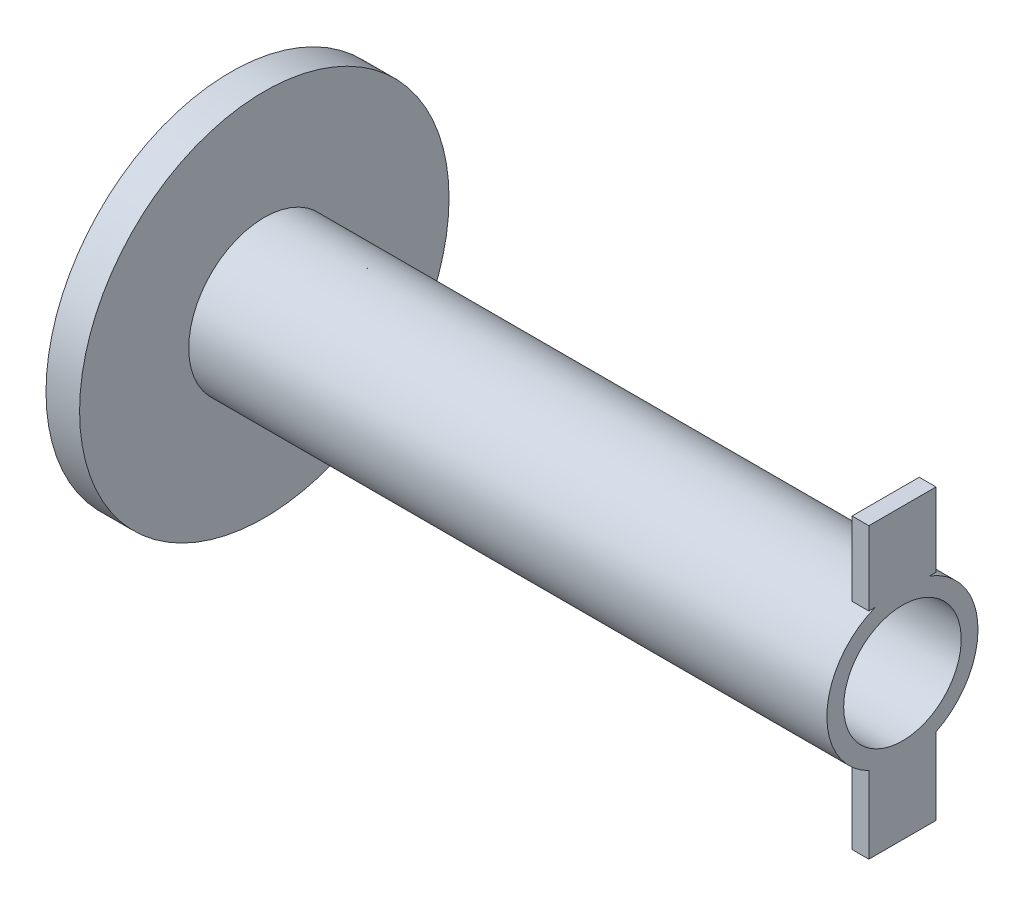
from build123d import *

# Parameters (mm, degrees)
SKETCH2_R               = 55
BOSS_EXTRUDE1_DEPTH     = 10
SKETCH3_R               = 22.5
BOSS_EXTRUDE2_DEPTH     = 190
SKETCH4_R               = 17.5
CUT_EXTRUDE1_DEPTH      = 1
CUT_EXTRUDE1_DEPTH_BACK = 201
SKETCH9_W               = 20
SKETCH9_H               = 22
BOSS_EXTRUDE3_DEPTH     = 5
SKETCH10_W              = 20
SKETCH10_H              = 23
BOSS_EXTRUDE4_DEPTH     = 5


with BuildPart() as part:
    # Sketch2 → Boss-Extrude1 (new body)
    with BuildSketch(Plane(origin=(0, 0, 0), x_dir=(0, 0, -1), z_dir=(1, 0, 0))):
        Circle(SKETCH2_R)
    extrude(amount=BOSS_EXTRUDE1_DEPTH)

    # Sketch3 → Boss-Extrude2 (add)
    with BuildSketch(Plane(origin=(10, 0, 0), x_dir=(0, 0, -1), z_dir=(1, 0, 0))):
        Circle(SKETCH3_R)
    extrude(amount=BOSS_EXTRUDE2_DEPTH)

    # Sketch4 → Cut-Extrude1 (cut, two sides)
    with BuildSketch(Plane.ZY) as cut_extrude1_sk:
        Circle(SKETCH4_R)
    extrude(amount=CUT_EXTRUDE1_DEPTH, mode=Mode.SUBTRACT)
    extrude(cut_extrude1_sk.sketch, amount=-CUT_EXTRUDE1_DEPTH_BACK, mode=Mode.SUBTRACT)

    # Sketch9 → Boss-Extrude3 (add)
    with BuildSketch(Plane(origin=(200, 0, 0), x_dir=(0, 0, -1), z_dir=(1, 0, 0))):
        with Locations((0, 32)):
            Rectangle(SKETCH9_W, SKETCH9_H)
    extrude(amount=-BOSS_EXTRUDE3_DEPTH)

    # Sketch10 → Boss-Extrude4 (add)
    with BuildSketch(Plane(origin=(200, 0, 0), x_dir=(0, 0, -1), z_dir=(1, 0, 0))):
        with Locations((0, -31.5)):
            Rectangle(SKETCH10_W, SKETCH10_H)
    extrude(amount=-BOSS_EXTRUDE4_DEPTH)


solid = part.part
